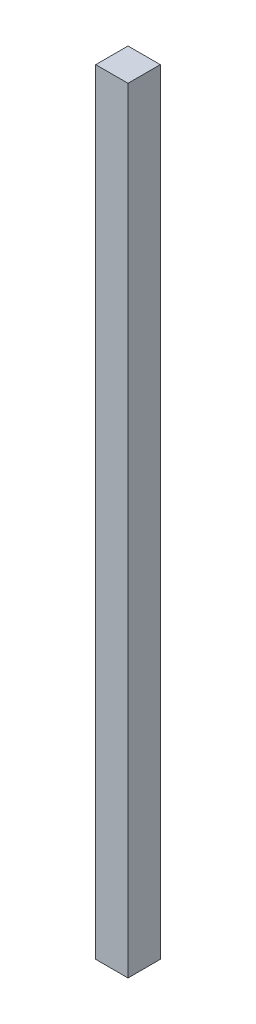
from build123d import *

# Parameters (mm, degrees)
SKETCH1_W           = 25.4
SKETCH1_H           = 25.4
BOSS_EXTRUDE1_DEPTH = 304.8


with BuildPart() as part:
    # Sketch1 → Boss-Extrude1 (new body, symmetric)
    with BuildSketch(Plane(origin=(0, 0, 0), x_dir=(1, 0, 0), z_dir=(0, 1, 0))):
        Rectangle(SKETCH1_W, SKETCH1_H)
    extrude(amount=BOSS_EXTRUDE1_DEPTH, both=True)


solid = part.part
